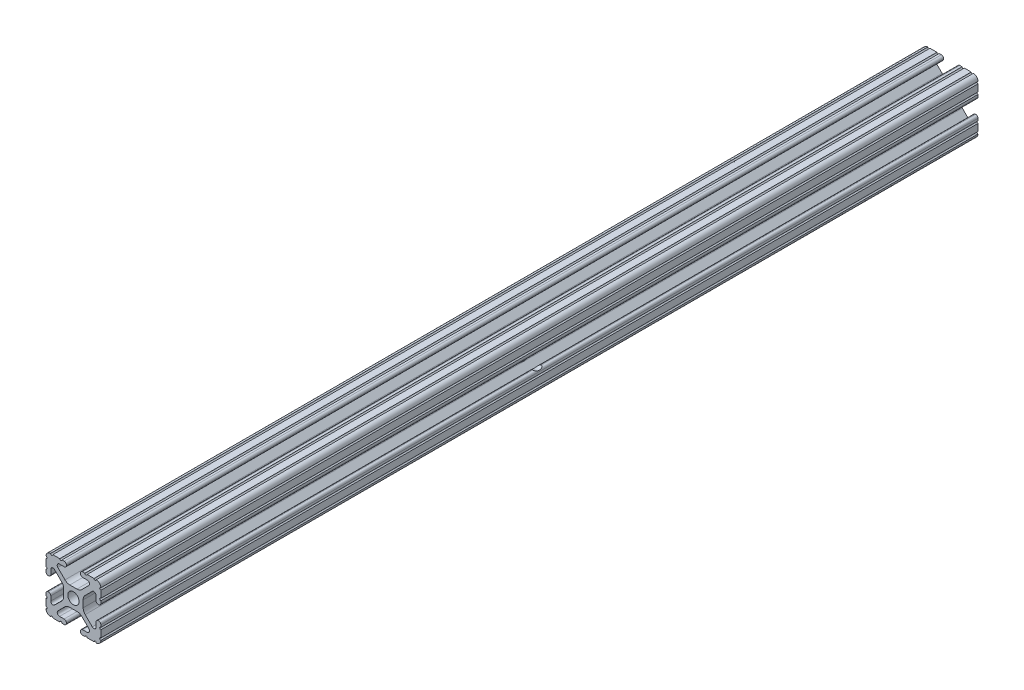
from build123d import *

# Parameters (mm, degrees)
SKETCH1_R               = 2.6035
BOSS_EXTRUDE1_DEPTH     = 203.2
SKETCH2_R               = 3.81
CUT_EXTRUDE1_DEPTH      = 25.4
SKETCH3_R               = 3.175
CUT_EXTRUDE2_DEPTH      = 205.321378179
CUT_EXTRUDE2_DEPTH_BACK = 205.321378179


with BuildPart() as part:
    # Sketch1 → Boss-Extrude1 (new, symmetric)
    with BuildSketch(Plane.XY):
        with BuildLine():
            Line((-7.179650497, -8.645192506), (-3.952270251, -5.423690499))
            ThreePointArc((-3.952270251, -5.423690499), (-2.922936451, -4.736929036), (-1.709253557, -4.4958))
            Line((-1.709253557, -4.4958), (1.709253557, -4.4958))
            ThreePointArc((1.709253557, -4.4958), (2.922936451, -4.736929036), (3.952270251, -5.423690499))
            Line((3.952270251, -5.423690499), (7.179650497, -8.645192506))
            ThreePointArc((7.179650497, -8.645192506), (7.41473083, -9.822813117), (6.416408329, -10.4902))
            Line((6.416408329, -10.4902), (4.287512407, -10.4902))
            ThreePointArc((4.287512407, -10.4902), (3.54574862, -10.79744862), (3.2385, -11.539212407))
            Line((3.2385, -11.539212407), (3.2385, -11.650987593))
            ThreePointArc((3.2385, -11.650987593), (3.54574862, -12.39275138), (4.287512407, -12.7))
            Line((4.287512407, -12.7), (5.317126718, -12.7))
            ThreePointArc((5.317126718, -12.7), (5.825126718, -12.192), (6.333126718, -12.7))
            Line((6.333126718, -12.7), (9.550443118, -12.7))
            ThreePointArc((9.550443118, -12.7), (10.058366869, -12.192000006), (10.566443095, -12.699847501))
            ThreePointArc((10.566443095, -12.699847501), (12.082537762, -12.08250727), (12.699846982, -10.566399977))
            ThreePointArc((12.699846982, -10.566399977), (12.192000006, -10.058323491), (12.7, -9.5504))
            Line((12.7, -9.5504), (12.7, -6.3330836))
            ThreePointArc((12.7, -6.3330836), (12.192, -5.8250836), (12.7, -5.3170836))
            Line((12.7, -5.3170836), (12.7, -4.287469289))
            ThreePointArc((12.7, -4.287469289), (12.39275138, -3.545705502), (11.650987593, -3.238456882))
            Line((11.650987593, -3.238456882), (11.539212407, -3.238456882))
            ThreePointArc((11.539212407, -3.238456882), (10.79744862, -3.545705502), (10.4902, -4.287469289))
            Line((10.4902, -4.287469289), (10.4902, -6.402089023))
            ThreePointArc((10.4902, -6.402089023), (9.856505071, -7.351067942), (8.737131347, -7.129408934))
            Line((8.737131347, -7.129408934), (5.441005833, -3.840816462))
            ThreePointArc((5.441005833, -3.840816462), (4.750877967, -2.809883091), (4.5085, -1.593185507))
            Line((4.5085, -1.593185507), (4.5085, 1.593185507))
            ThreePointArc((4.5085, 1.593185507), (4.750877967, 2.809883091), (5.441005833, 3.840816462))
            Line((5.441005833, 3.840816462), (8.737131347, 7.129408934))
            ThreePointArc((8.737131347, 7.129408934), (9.856505071, 7.351067942), (10.4902, 6.402089023))
            Line((10.4902, 6.402089023), (10.4902, 4.287469289))
            ThreePointArc((10.4902, 4.287469289), (10.79744862, 3.545705502), (11.539212407, 3.238456882))
            Line((11.539212407, 3.238456882), (11.650987593, 3.238456882))
            ThreePointArc((11.650987593, 3.238456882), (12.39275138, 3.545705502), (12.7, 4.287469289))
            Line((12.7, 4.287469289), (12.7, 5.3170836))
            ThreePointArc((12.7, 5.3170836), (12.192, 5.8250836), (12.7, 6.3330836))
            Line((12.7, 6.3330836), (12.7, 9.5504))
            ThreePointArc((12.7, 9.5504), (12.192000006, 10.058323491), (12.699846982, 10.566399977))
            ThreePointArc((12.699846982, 10.566399977), (12.082537762, 12.08250727), (10.566443095, 12.699847501))
            ThreePointArc((10.566443095, 12.699847501), (10.058366869, 12.192000006), (9.550443118, 12.7))
            Line((9.550443118, 12.7), (6.333126718, 12.7))
            ThreePointArc((6.333126718, 12.7), (5.825126718, 12.192), (5.317126718, 12.7))
            Line((5.317126718, 12.7), (4.287512407, 12.7))
            ThreePointArc((4.287512407, 12.7), (3.54574862, 12.39275138), (3.2385, 11.650987593))
            Line((3.2385, 11.650987593), (3.2385, 11.539212407))
            ThreePointArc((3.2385, 11.539212407), (3.54574862, 10.79744862), (4.287512407, 10.4902))
            Line((4.287512407, 10.4902), (6.476788598, 10.4902))
            ThreePointArc((6.476788598, 10.4902), (7.432222385, 9.85140422), (7.207036008, 8.724370562))
            Line((7.207036008, 8.724370562), (3.898272566, 5.423169045))
            ThreePointArc((3.898272566, 5.423169045), (2.869120213, 4.736787962), (1.655778399, 4.4958))
            Line((1.655778399, 4.4958), (-1.655778399, 4.4958))
            ThreePointArc((-1.655778399, 4.4958), (-2.869120213, 4.736787962), (-3.898272566, 5.423169045))
            Line((-3.898272566, 5.423169045), (-7.207036008, 8.724370562))
            ThreePointArc((-7.207036008, 8.724370562), (-7.432222385, 9.85140422), (-6.476788598, 10.4902))
            Line((-6.476788598, 10.4902), (-4.287512407, 10.4902))
            ThreePointArc((-4.287512407, 10.4902), (-3.54574862, 10.79744862), (-3.2385, 11.539212407))
            Line((-3.2385, 11.539212407), (-3.2385, 11.650987593))
            ThreePointArc((-3.2385, 11.650987593), (-3.54574862, 12.39275138), (-4.287512407, 12.7))
            Line((-4.287512407, 12.7), (-5.317126718, 12.7))
            ThreePointArc((-5.317126718, 12.7), (-5.825126718, 12.192), (-6.333126718, 12.7))
            Line((-6.333126718, 12.7), (-9.550443118, 12.7))
            ThreePointArc((-9.550443118, 12.7), (-10.058366869, 12.192000006), (-10.566443095, 12.699847501))
            ThreePointArc((-10.566443095, 12.699847501), (-12.082537762, 12.08250727), (-12.699846982, 10.566399977))
            ThreePointArc((-12.699846982, 10.566399977), (-12.192000006, 10.058323491), (-12.7, 9.5504))
            Line((-12.7, 9.5504), (-12.7, 6.3330836))
            ThreePointArc((-12.7, 6.3330836), (-12.192, 5.8250836), (-12.7, 5.3170836))
            Line((-12.7, 5.3170836), (-12.7, 4.287469289))
            ThreePointArc((-12.7, 4.287469289), (-12.39275138, 3.545705502), (-11.650987593, 3.238456882))
            Line((-11.650987593, 3.238456882), (-11.539212407, 3.238456882))
            ThreePointArc((-11.539212407, 3.238456882), (-10.79744862, 3.545705502), (-10.4902, 4.287469289))
            Line((-10.4902, 4.287469289), (-10.4902, 6.402089023))
            ThreePointArc((-10.4902, 6.402089023), (-9.856505071, 7.351067942), (-8.737131347, 7.129408934))
            Line((-8.737131347, 7.129408934), (-5.441005833, 3.840816462))
            ThreePointArc((-5.441005833, 3.840816462), (-4.750877967, 2.809883091), (-4.5085, 1.593185507))
            Line((-4.5085, 1.593185507), (-4.5085, -1.593185507))
            ThreePointArc((-4.5085, -1.593185507), (-4.750877967, -2.809883091), (-5.441005833, -3.840816462))
            Line((-5.441005833, -3.840816462), (-8.737131347, -7.129408934))
            ThreePointArc((-8.737131347, -7.129408934), (-9.856505071, -7.351067942), (-10.4902, -6.402089023))
            Line((-10.4902, -6.402089023), (-10.4902, -4.287469289))
            ThreePointArc((-10.4902, -4.287469289), (-10.79744862, -3.545705502), (-11.539212407, -3.238456882))
            Line((-11.539212407, -3.238456882), (-11.650987593, -3.238456882))
            ThreePointArc((-11.650987593, -3.238456882), (-12.39275138, -3.545705502), (-12.7, -4.287469289))
            Line((-12.7, -4.287469289), (-12.7, -5.3170836))
            ThreePointArc((-12.7, -5.3170836), (-12.192, -5.8250836), (-12.7, -6.3330836))
            Line((-12.7, -6.3330836), (-12.7, -9.5504))
            ThreePointArc((-12.7, -9.5504), (-12.192000006, -10.058323491), (-12.699846982, -10.566399977))
            ThreePointArc((-12.699846982, -10.566399977), (-12.082537762, -12.08250727), (-10.566443095, -12.699847501))
            ThreePointArc((-10.566443095, -12.699847501), (-10.058366869, -12.192000006), (-9.550443118, -12.7))
            Line((-9.550443118, -12.7), (-6.333126718, -12.7))
            ThreePointArc((-6.333126718, -12.7), (-5.825126718, -12.192), (-5.317126718, -12.7))
            Line((-5.317126718, -12.7), (-4.287512407, -12.7))
            ThreePointArc((-4.287512407, -12.7), (-3.54574862, -12.39275138), (-3.2385, -11.650987593))
            Line((-3.2385, -11.650987593), (-3.2385, -11.539212407))
            ThreePointArc((-3.2385, -11.539212407), (-3.54574862, -10.79744862), (-4.287512407, -10.4902))
            Line((-4.287512407, -10.4902), (-6.416408329, -10.4902))
            ThreePointArc((-6.416408329, -10.4902), (-7.41473083, -9.822813117), (-7.179650497, -8.645192506))
        make_face()
        Circle(SKETCH1_R, mode=Mode.SUBTRACT)
    extrude(amount=BOSS_EXTRUDE1_DEPTH, both=True)

    # Sketch2 → Cut-Extrude1 (cut)
    with BuildSketch(Plane.ZY.offset(12.7)):
        with Locations(Location((0, 0, 0), (0, 0, 24.718407228))):
            Circle(SKETCH2_R)
    extrude(amount=-CUT_EXTRUDE1_DEPTH, mode=Mode.SUBTRACT)

    # Sketch3 → Cut-Extrude2 (cut, two sides)
    with BuildSketch(Plane(origin=(0, 4.4958, 0), x_dir=(1, 0, 0), z_dir=(0, 1, 0))) as cut_extrude2_sk:
        with Locations(Location((0, -190.5, 0), (0, 0, 237.428778052))):
            Circle(SKETCH3_R)
        with Locations(Location((0, 190.5, 0), (0, 0, 237.428778052))):
            Circle(SKETCH3_R)
    extrude(amount=CUT_EXTRUDE2_DEPTH, mode=Mode.SUBTRACT)
    extrude(cut_extrude2_sk.sketch, amount=-CUT_EXTRUDE2_DEPTH_BACK, mode=Mode.SUBTRACT)


solid = part.part
